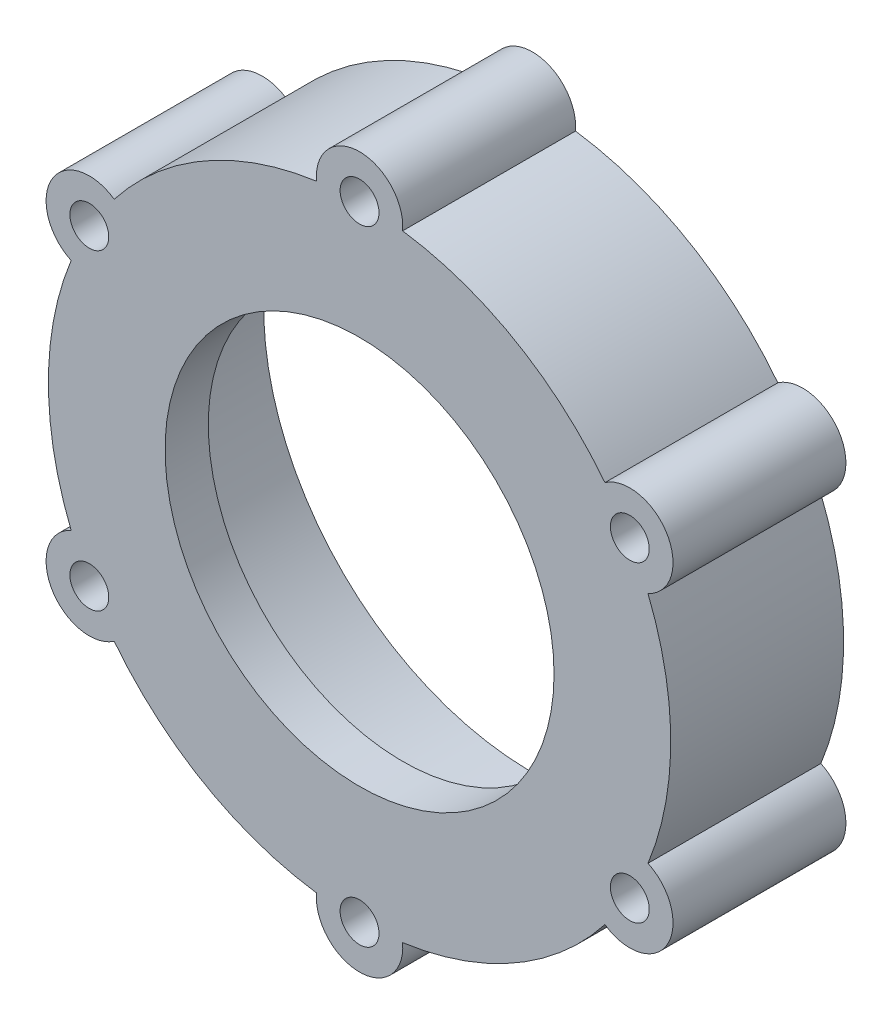
from build123d import *

# Parameters (mm, degrees)
SKETCH1_R           = 36
SKETCH1_R_2         = 31.1
BOSS_EXTRUDE1_DEPTH = 15
SKETCH2_R           = 36
BOSS_EXTRUDE2_DEPTH = 5
SKETCH3_R           = 22.5
CUT_EXTRUDE1_DEPTH  = 5
SKETCH4_R           = 5
BOSS_EXTRUDE3_DEPTH = 20
SKETCH7_R           = 2.25
CUT_EXTRUDE2_DEPTH  = 21


with BuildPart() as part:
    # Sketch1 → Boss-Extrude1 (new body)
    with BuildSketch(Plane.XY):
        Circle(SKETCH1_R)
        Circle(SKETCH1_R_2, mode=Mode.SUBTRACT)
    extrude(amount=BOSS_EXTRUDE1_DEPTH)

    # Sketch2 → Boss-Extrude2 (add)
    with BuildSketch(Plane.XY.offset(15)):
        Circle(SKETCH2_R)
    extrude(amount=BOSS_EXTRUDE2_DEPTH)

    # Sketch3 → Cut-Extrude1 (cut)
    with BuildSketch(Plane.XY.offset(20)):
        Circle(SKETCH3_R)
    extrude(amount=-CUT_EXTRUDE1_DEPTH, mode=Mode.SUBTRACT)

    # Sketch4 → Boss-Extrude3 (add)
    with BuildSketch(Plane(origin=(0, 0, 0), x_dir=(-1, 0, 0), z_dir=(0, 0, -1))):
        with Locations((0, 36.1)):
            Circle(SKETCH4_R)
        with Locations((31.263517077, 18.05)):
            Circle(SKETCH4_R)
        with Locations((31.263517077, -18.05)):
            Circle(SKETCH4_R)
        with Locations((0, -36.1)):
            Circle(SKETCH4_R)
        with Locations((-31.263517077, -18.05)):
            Circle(SKETCH4_R)
        with Locations((-31.263517077, 18.05)):
            Circle(SKETCH4_R)
    extrude(amount=-BOSS_EXTRUDE3_DEPTH)

    # Sketch7 → Cut-Extrude2 (cut, through all)
    with BuildSketch(Plane(origin=(0, 0, 0), x_dir=(-1, 0, 0), z_dir=(0, 0, -1))):
        with Locations((-31.263517077, 18.05)):
            Circle(SKETCH7_R)
        with Locations((0, 36.1)):
            Circle(SKETCH7_R)
        with Locations((31.263517077, 18.05)):
            Circle(SKETCH7_R)
        with Locations((31.263517077, -18.05)):
            Circle(SKETCH7_R)
        with Locations((0, -36.1)):
            Circle(SKETCH7_R)
        with Locations((-31.263517077, -18.05)):
            Circle(SKETCH7_R)
    extrude(amount=-CUT_EXTRUDE2_DEPTH, mode=Mode.SUBTRACT)


solid = part.part
